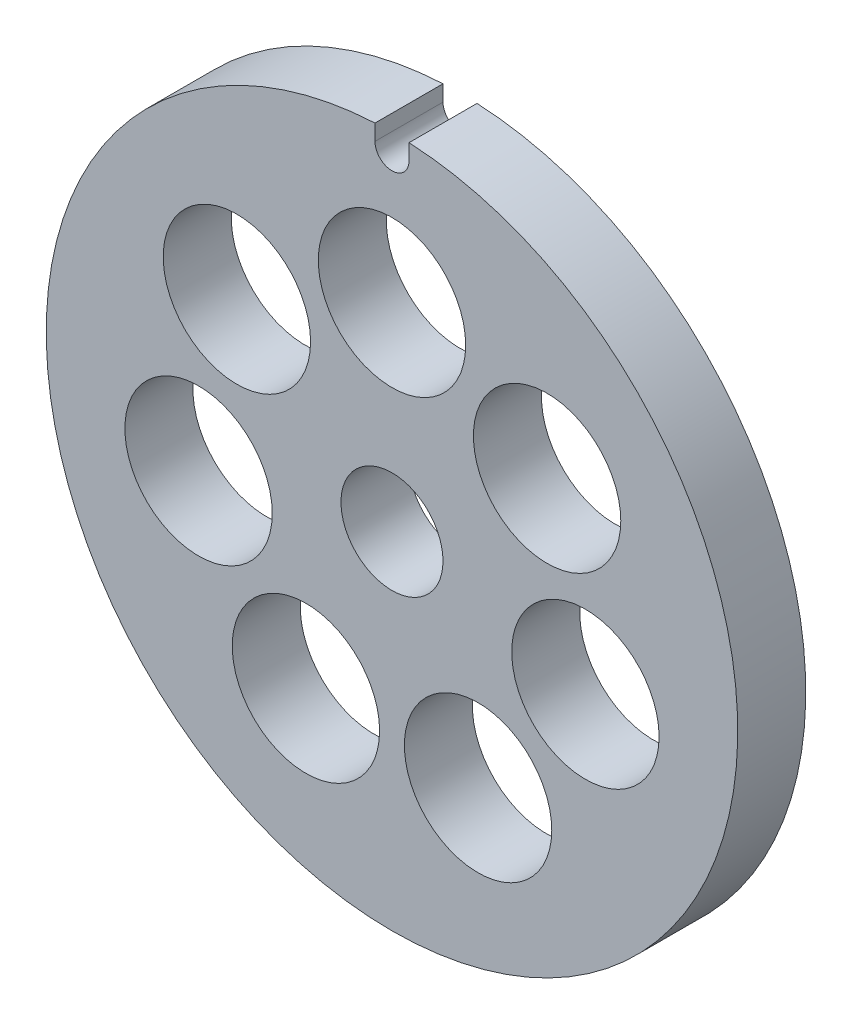
from build123d import *

# Parameters (mm, degrees)
SZKIC1_R                    = 4.5
SZKIC1_R_2                  = 6.5
DODANIE_WYCI_GNI_CIE2_DEPTH = 6


with BuildPart() as part:
    # Szkic1 → Dodanie-wyciągnięcie2 (new body)
    with BuildSketch(Plane.XY):
        with BuildLine():
            Line((-1.5, 30.463092423), (-1.5, 29.063092423))
            ThreePointArc((-1.5, 29.063092423), (0, 27.563092423), (1.5, 29.063092423))
            Line((1.5, 29.063092423), (1.5, 30.463092423))
            ThreePointArc((1.5, 30.463092423), (0, -30.5), (-1.5, 30.463092423))
        make_face()
        Circle(SZKIC1_R, mode=Mode.SUBTRACT)
        with Locations((0, 17.5)):
            Circle(SZKIC1_R_2, mode=Mode.SUBTRACT)
        with Locations((13.682050943, 10.911071533)):
            Circle(SZKIC1_R_2, mode=Mode.SUBTRACT)
        with Locations((17.061238463, -3.894116344)):
            Circle(SZKIC1_R_2, mode=Mode.SUBTRACT)
        with Locations((7.592965435, -15.766955188)):
            Circle(SZKIC1_R_2, mode=Mode.SUBTRACT)
        with Locations((-7.592965435, -15.766955188)):
            Circle(SZKIC1_R_2, mode=Mode.SUBTRACT)
        with Locations((-17.061238463, -3.894116344)):
            Circle(SZKIC1_R_2, mode=Mode.SUBTRACT)
        with Locations((-13.682050943, 10.911071533)):
            Circle(SZKIC1_R_2, mode=Mode.SUBTRACT)
    extrude(amount=DODANIE_WYCI_GNI_CIE2_DEPTH)


solid = part.part
